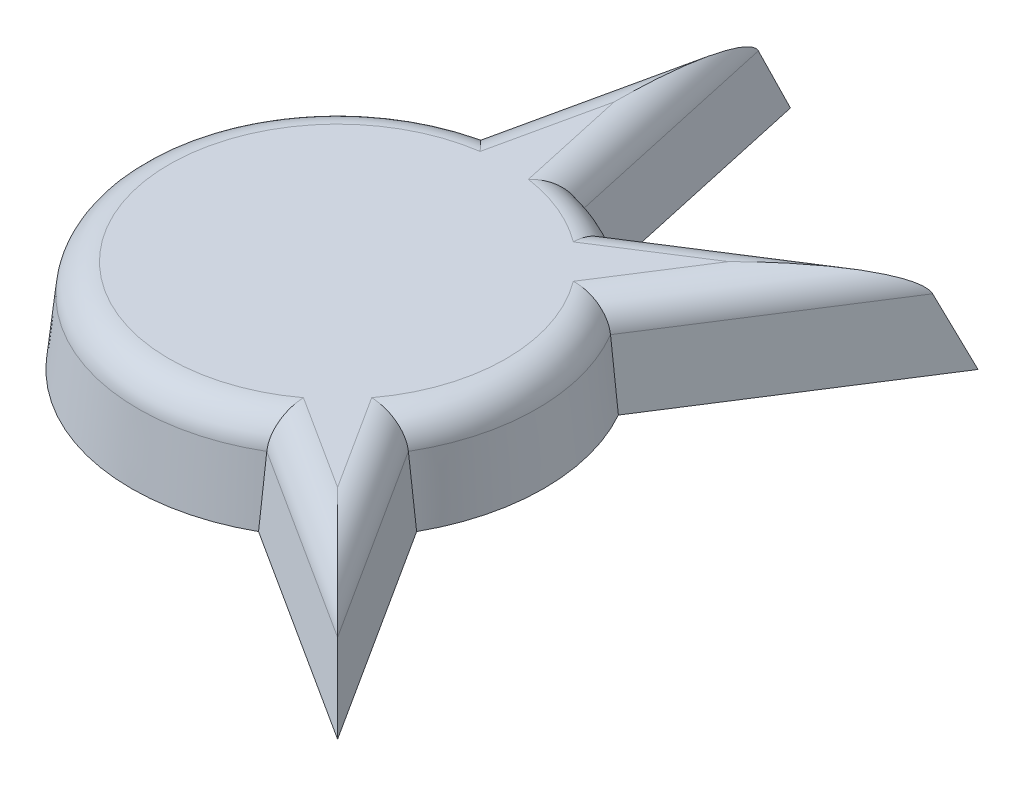
from build123d import *

# Parameters (mm, degrees)
BOSS_EXTRUDE1_DEPTH = 3
BOSS_EXTRUDE1_TAPER = 6
FILLET1_R           = 1


with BuildPart() as part:
    # Sketch2 → Boss-Extrude1 (new body)
    with BuildSketch(Plane(origin=(0, 0, 0), x_dir=(1, 0, 0), z_dir=(0, 1, 0))):
        with BuildLine():
            Line((1.794958228, 6.376825284), (0, 14.54359673))
            Line((0, 14.54359673), (-1.794958228, 6.376825284))
            ThreePointArc((-1.794958228, 6.376825284), (-6.120363771, -2.535137681), (3.239869266, -5.778323536))
            Line((3.239869266, -5.778323536), (10.283875871, -10.283875871))
            Line((10.283875871, -10.283875871), (5.778323536, -3.239869266))
            ThreePointArc((5.778323536, -3.239869266), (6.624634009, 0), (5.778323536, 3.239869266))
            Line((5.778323536, 3.239869266), (10.283875871, 10.283875871))
            Line((10.283875871, 10.283875871), (3.239869266, 5.778323536))
            ThreePointArc((3.239869266, 5.778323536), (2.535137681, 6.120363771), (1.794958228, 6.376825284))
        make_face()
    extrude(amount=BOSS_EXTRUDE1_DEPTH, taper=BOSS_EXTRUDE1_TAPER)

    # Fillet1
    fillet1_edges = [part.edges().sort_by_distance(p)[0] for p in [
        (-5.829052816, 3, 2.414472732),
        (-0.764125431, 3, -9.598084382),
        (0.764125431, 3, -9.598084382),
        (2.414472732, 3, -5.829052816),
        (6.246552279, 3, -7.327188827),
        (7.327188827, 3, -6.246552279),
        (6.309321303, 3, 0),
        (7.327188827, 3, 6.246552279),
        (6.246552279, 3, 7.327188827),
    ]]
    fillet(fillet1_edges, radius=FILLET1_R)


solid = part.part
